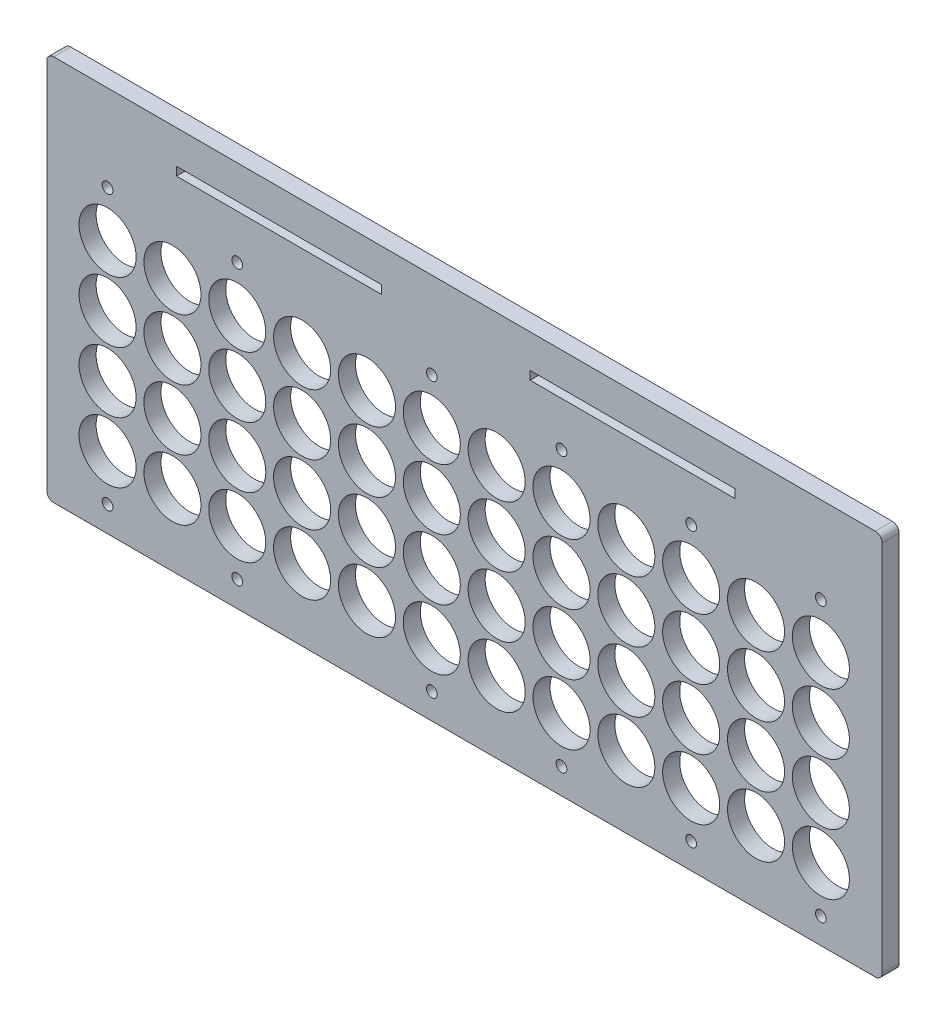
from build123d import *

# Parameters (mm, degrees)
SKETCH2_R               = 10.6172
SKETCH2_R_2             = 2
BOSS_EXTRUDE1_DEPTH     = 6.35
SKETCH5_W               = 3.175
SKETCH5_H               = 121.076
BOSS_EXTRUDE2_DEPTH     = 6.35
SKETCH8_W               = 310.828126018
SKETCH8_H               = 22.616973562
BOSS_EXTRUDE4_DEPTH     = 6.35
FILLET2_R               = 2.54
SKETCH11_W              = 76.2
SKETCH11_H              = 3.175
CUT_EXTRUDE3_DEPTH      = 1
CUT_EXTRUDE3_DEPTH_BACK = 7.35


with BuildPart() as part:
    # Sketch2 → Boss-Extrude1 (new body)
    with BuildSketch(Plane.XY):
        Polygon((-19.430000002, 91.526), (-19.430000002, -23.708), (-19.430000002, -26.629), (285.048126016, -26.629), (285.048126016, -23.708), (285.048126016, 91.526), (285.048126016, 94.447), (-19.430000002, 94.447), align=None)
        Circle(SKETCH2_R, mode=Mode.SUBTRACT)
        with Locations((24.13, 0)):
            Circle(SKETCH2_R, mode=Mode.SUBTRACT)
        with Locations((48.26, 0)):
            Circle(SKETCH2_R, mode=Mode.SUBTRACT)
        with Locations((72.39, 0)):
            Circle(SKETCH2_R, mode=Mode.SUBTRACT)
        with Locations((24.13, 22.606)):
            Circle(SKETCH2_R, mode=Mode.SUBTRACT)
        with Locations((48.26, 22.606)):
            Circle(SKETCH2_R, mode=Mode.SUBTRACT)
        with Locations((72.39, 22.606)):
            Circle(SKETCH2_R, mode=Mode.SUBTRACT)
        with Locations((24.13, 45.212)):
            Circle(SKETCH2_R, mode=Mode.SUBTRACT)
        with Locations((48.26, 45.212)):
            Circle(SKETCH2_R, mode=Mode.SUBTRACT)
        with Locations((72.39, 45.212)):
            Circle(SKETCH2_R, mode=Mode.SUBTRACT)
        with Locations((24.13, 67.818)):
            Circle(SKETCH2_R, mode=Mode.SUBTRACT)
        with Locations((48.26, 67.818)):
            Circle(SKETCH2_R, mode=Mode.SUBTRACT)
        with Locations((72.39, 67.818)):
            Circle(SKETCH2_R, mode=Mode.SUBTRACT)
        with Locations((0, 22.606)):
            Circle(SKETCH2_R, mode=Mode.SUBTRACT)
        with Locations((0, 45.212)):
            Circle(SKETCH2_R, mode=Mode.SUBTRACT)
        with Locations((0, 67.818)):
            Circle(SKETCH2_R, mode=Mode.SUBTRACT)
        with Locations((96.52, 0)):
            Circle(SKETCH2_R, mode=Mode.SUBTRACT)
        with Locations((120.65, 0)):
            Circle(SKETCH2_R, mode=Mode.SUBTRACT)
        with Locations((144.78, 0)):
            Circle(SKETCH2_R, mode=Mode.SUBTRACT)
        with Locations((168.91, 0)):
            Circle(SKETCH2_R, mode=Mode.SUBTRACT)
        with Locations((193.04, 0)):
            Circle(SKETCH2_R, mode=Mode.SUBTRACT)
        with Locations((217.17, 0)):
            Circle(SKETCH2_R, mode=Mode.SUBTRACT)
        with Locations((241.3, 0)):
            Circle(SKETCH2_R, mode=Mode.SUBTRACT)
        with Locations((265.43, 0)):
            Circle(SKETCH2_R, mode=Mode.SUBTRACT)
        with Locations((96.52, 22.606)):
            Circle(SKETCH2_R, mode=Mode.SUBTRACT)
        with Locations((120.65, 22.606)):
            Circle(SKETCH2_R, mode=Mode.SUBTRACT)
        with Locations((144.78, 22.606)):
            Circle(SKETCH2_R, mode=Mode.SUBTRACT)
        with Locations((168.91, 22.606)):
            Circle(SKETCH2_R, mode=Mode.SUBTRACT)
        with Locations((193.04, 22.606)):
            Circle(SKETCH2_R, mode=Mode.SUBTRACT)
        with Locations((217.17, 22.606)):
            Circle(SKETCH2_R, mode=Mode.SUBTRACT)
        with Locations((241.3, 22.606)):
            Circle(SKETCH2_R, mode=Mode.SUBTRACT)
        with Locations((265.43, 22.606)):
            Circle(SKETCH2_R, mode=Mode.SUBTRACT)
        with Locations((96.52, 45.212)):
            Circle(SKETCH2_R, mode=Mode.SUBTRACT)
        with Locations((120.65, 45.212)):
            Circle(SKETCH2_R, mode=Mode.SUBTRACT)
        with Locations((144.78, 45.212)):
            Circle(SKETCH2_R, mode=Mode.SUBTRACT)
        with Locations((168.91, 45.212)):
            Circle(SKETCH2_R, mode=Mode.SUBTRACT)
        with Locations((193.04, 45.212)):
            Circle(SKETCH2_R, mode=Mode.SUBTRACT)
        with Locations((217.17, 45.212)):
            Circle(SKETCH2_R, mode=Mode.SUBTRACT)
        with Locations((241.3, 45.212)):
            Circle(SKETCH2_R, mode=Mode.SUBTRACT)
        with Locations((265.43, 45.212)):
            Circle(SKETCH2_R, mode=Mode.SUBTRACT)
        with Locations((96.52, 67.818)):
            Circle(SKETCH2_R, mode=Mode.SUBTRACT)
        with Locations((120.65, 67.818)):
            Circle(SKETCH2_R, mode=Mode.SUBTRACT)
        with Locations((144.78, 67.818)):
            Circle(SKETCH2_R, mode=Mode.SUBTRACT)
        with Locations((168.91, 67.818)):
            Circle(SKETCH2_R, mode=Mode.SUBTRACT)
        with Locations((193.04, 67.818)):
            Circle(SKETCH2_R, mode=Mode.SUBTRACT)
        with Locations((217.17, 67.818)):
            Circle(SKETCH2_R, mode=Mode.SUBTRACT)
        with Locations((241.3, 67.818)):
            Circle(SKETCH2_R, mode=Mode.SUBTRACT)
        with Locations((265.43, 67.818)):
            Circle(SKETCH2_R, mode=Mode.SUBTRACT)
        with Locations((0, 84.921973416)):
            Circle(SKETCH2_R_2, mode=Mode.SUBTRACT)
        with Locations((48.26, 84.921973416)):
            Circle(SKETCH2_R_2, mode=Mode.SUBTRACT)
        with Locations((217.17, 84.921973416)):
            Circle(SKETCH2_R_2, mode=Mode.SUBTRACT)
        with Locations((265.43, 84.921973416)):
            Circle(SKETCH2_R_2, mode=Mode.SUBTRACT)
        with Locations((120.65, 84.921973416)):
            Circle(SKETCH2_R_2, mode=Mode.SUBTRACT)
        with Locations((168.91, 84.921973416)):
            Circle(SKETCH2_R_2, mode=Mode.SUBTRACT)
        with Locations((265.43, -17.103973416)):
            Circle(SKETCH2_R_2, mode=Mode.SUBTRACT)
        with Locations((217.17, -17.103973416)):
            Circle(SKETCH2_R_2, mode=Mode.SUBTRACT)
        with Locations((48.26, -17.103973416)):
            Circle(SKETCH2_R_2, mode=Mode.SUBTRACT)
        with Locations((0, -17.103973416)):
            Circle(SKETCH2_R_2, mode=Mode.SUBTRACT)
        with Locations((168.91, -17.103973416)):
            Circle(SKETCH2_R_2, mode=Mode.SUBTRACT)
        with Locations((120.65, -17.103973416)):
            Circle(SKETCH2_R_2, mode=Mode.SUBTRACT)
    extrude(amount=BOSS_EXTRUDE1_DEPTH)

    # Sketch5 → Boss-Extrude2 (add, through all)
    with BuildSketch(Plane.XY.offset(6.35)):
        with Locations((-21.017500002, 33.909)):
            Rectangle(SKETCH5_W, SKETCH5_H)
        with Locations((286.635626016, 33.909)):
            Rectangle(SKETCH5_W, SKETCH5_H)
    extrude(amount=-BOSS_EXTRUDE2_DEPTH)

    # Sketch8 → Boss-Extrude4 (add, through all)
    with BuildSketch(Plane.XY.offset(6.35)):
        with Locations((132.809063007, 105.755486781)):
            Rectangle(SKETCH8_W, SKETCH8_H)
    extrude(amount=-BOSS_EXTRUDE4_DEPTH)

    # Fillet2
    fillet2_edges = [part.edges().sort_by_distance(p)[0] for p in [
        (-22.605000002, -26.629, 3.175),
        (288.223126016, -26.629, 3.175),
        (-22.605000002, 117.063973562, 3.175),
        (288.223126016, 117.063973562, 3.175),
    ]]
    fillet(fillet2_edges, radius=FILLET2_R)

    # Sketch11 → Cut-Extrude3 (cut, two sides)
    with BuildSketch(Plane.XY.offset(6.35)) as cut_extrude3_sk:
        with Locations((195.322823422, 103.060954702)):
            Rectangle(SKETCH11_W, SKETCH11_H)
        with Locations((63.757176578, 103.060954702)):
            Rectangle(SKETCH11_W, SKETCH11_H)
    extrude(amount=CUT_EXTRUDE3_DEPTH, mode=Mode.SUBTRACT)
    extrude(cut_extrude3_sk.sketch, amount=-CUT_EXTRUDE3_DEPTH_BACK, mode=Mode.SUBTRACT)


solid = part.part
